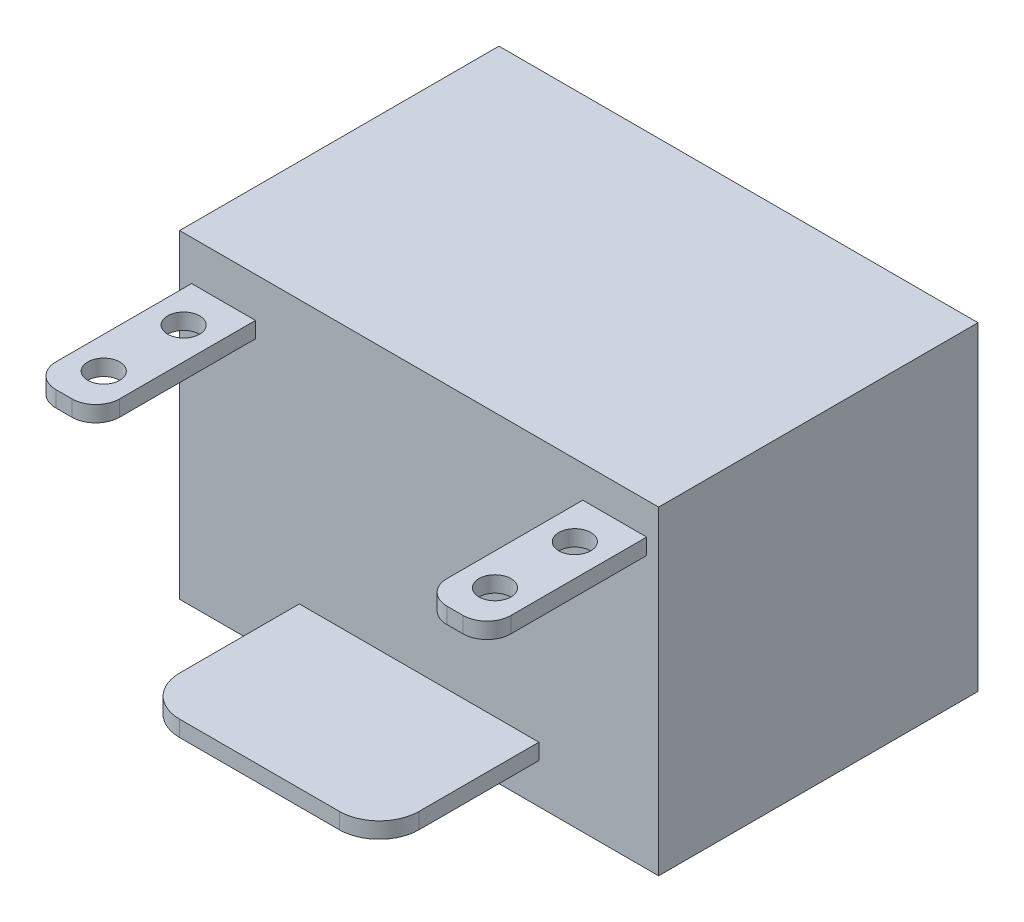
from build123d import *

# Parameters (mm, degrees)
IZIM1_W                     = 60
IZIM1_H                     = 40
Y_KSEKLIK_EKSTR_ZYON1_DEPTH = 40
IZIM1_3_W                   = 8
IZIM1_3_H                   = 2
IZIM1_3_W_2                 = 30
Y_KSEKLIK_EKSTR_ZYON2_DEPTH = 20
IZIM4_R                     = 2
KES_EKSTR_ZYON1_DEPTH       = 62.611687203
KES_EKSTR_ZYON2_DEPTH       = 20


with BuildPart() as part:
    # Çizim1 → Yükseklik-Ekstrüzyon1 (new body)
    with BuildSketch(Plane.XY):
        Rectangle(IZIM1_W, IZIM1_H)
    extrude(amount=-Y_KSEKLIK_EKSTR_ZYON1_DEPTH)

    # Çizim1<3> → Yükseklik-Ekstrüzyon2 (add)
    with BuildSketch(Plane.XY):
        with Locations((-24.5, 14)):
            Rectangle(IZIM1_3_W, IZIM1_3_H)
        with Locations((24.5, 15)):
            Rectangle(IZIM1_3_W, IZIM1_3_H)
        with Locations((0, -14)):
            Rectangle(IZIM1_3_W_2, IZIM1_3_H)
    extrude(amount=Y_KSEKLIK_EKSTR_ZYON2_DEPTH)

    # Çizim4 → Kes-Ekstrüzyon1 (cut, through all)
    with BuildSketch(Plane(origin=(0, 16, 0), x_dir=(1, 0, 0), z_dir=(0, 1, 0))):
        with BuildLine():
            ThreePointArc((-25.5, -20), (-27.621320344, -19.121320344), (-28.5, -17))
            Line((-28.5, -17), (-28.5, -20))
            Line((-28.5, -20), (-25.5, -20))
        make_face()
        with BuildLine():
            Line((-20.5, -20), (-20.5, -17))
            ThreePointArc((-20.5, -17), (-21.378679656, -19.121320344), (-23.5, -20))
            Line((-23.5, -20), (-20.5, -20))
        make_face()
        with BuildLine():
            ThreePointArc((23.5, -20), (21.378679656, -19.121320344), (20.5, -17))
            Line((20.5, -17), (20.5, -20))
            Line((20.5, -20), (23.5, -20))
        make_face()
        with BuildLine():
            Line((28.5, -20), (28.5, -17))
            ThreePointArc((28.5, -17), (27.621320344, -19.121320344), (25.5, -20))
            Line((25.5, -20), (28.5, -20))
        make_face()
        with Locations((24.5, -5)):
            Circle(IZIM4_R)
        with Locations((24.5, -15)):
            Circle(IZIM4_R)
        with Locations((-24.5, -5)):
            Circle(IZIM4_R)
        with Locations((-24.5, -15)):
            Circle(IZIM4_R)
    extrude(amount=-KES_EKSTR_ZYON1_DEPTH, mode=Mode.SUBTRACT)

    # Çizim5 → Kes-Ekstrüzyon2 (cut)
    with BuildSketch(Plane.XZ.offset(15)):
        with BuildLine():
            Line((-15, 20), (-15, 15))
            ThreePointArc((-15, 15), (-13.535533906, 18.535533906), (-10, 20))
            Line((-10, 20), (-15, 20))
        make_face()
        with BuildLine():
            Line((15, 20), (10, 20))
            ThreePointArc((10, 20), (13.535533906, 18.535533906), (15, 15))
            Line((15, 15), (15, 20))
        make_face()
    extrude(amount=-KES_EKSTR_ZYON2_DEPTH, mode=Mode.SUBTRACT)


solid = part.part
